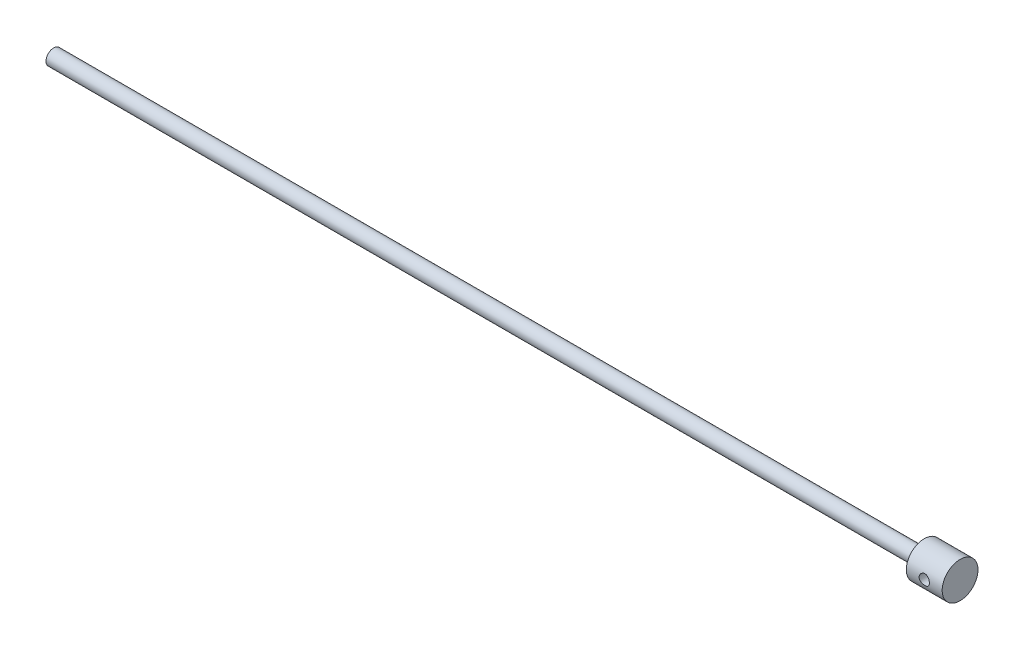
from build123d import *

# Parameters (mm, degrees)
SKETCH1_R               = 7.5
BOSS_EXTRUDE1_DEPTH     = 850
SKETCH2_R               = 17.5
BOSS_EXTRUDE2_DEPTH     = 35
SKETCH3_R               = 5
CUT_EXTRUDE2_DEPTH      = 18.5
CUT_EXTRUDE2_DEPTH_BACK = 18.5


with BuildPart() as part:
    # Sketch1 → Boss-Extrude1 (new body)
    with BuildSketch(Plane(origin=(0, 0, 0), x_dir=(0, 0, -1), z_dir=(1, 0, 0))):
        Circle(SKETCH1_R)
    extrude(amount=-BOSS_EXTRUDE1_DEPTH)

    # Sketch2 → Boss-Extrude2 (add)
    with BuildSketch(Plane(origin=(0, 0, 0), x_dir=(0, 0, -1), z_dir=(1, 0, 0))):
        Circle(SKETCH2_R)
    extrude(amount=BOSS_EXTRUDE2_DEPTH)

    # Sketch3 → Cut-Extrude2 (cut, two sides)
    with BuildSketch(Plane.XY) as cut_extrude2_sk:
        with Locations((17.5, 0)):
            Circle(SKETCH3_R)
    extrude(amount=CUT_EXTRUDE2_DEPTH, mode=Mode.SUBTRACT)
    extrude(cut_extrude2_sk.sketch, amount=-CUT_EXTRUDE2_DEPTH_BACK, mode=Mode.SUBTRACT)


solid = part.part
